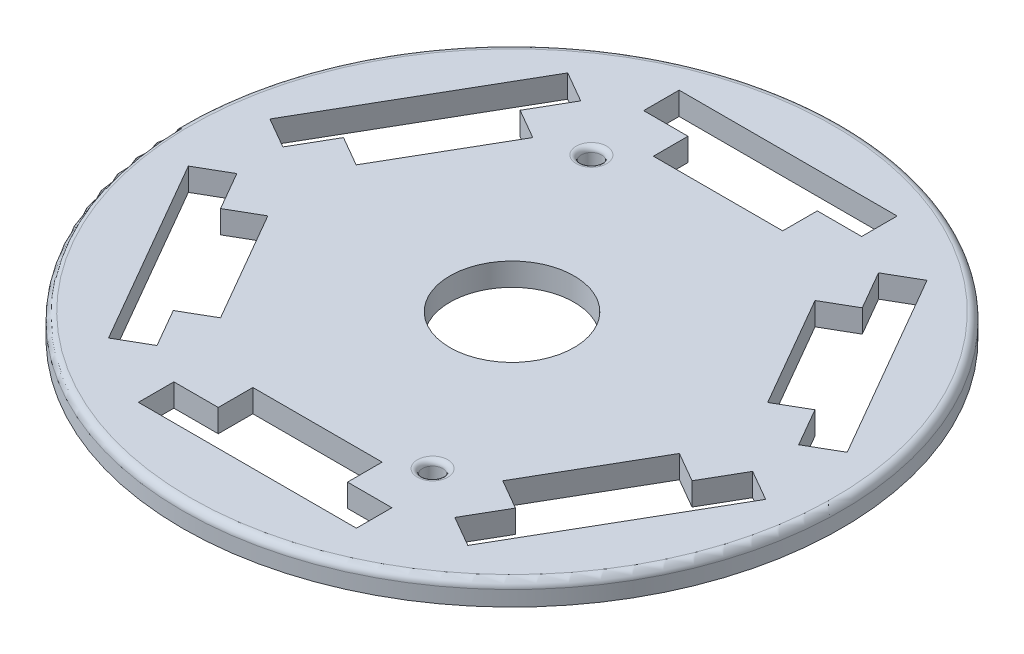
from build123d import *

# Parameters (mm, degrees)
SKETCH1_R           = 32.5
BOSS_EXTRUDE1_DEPTH = 2.25
SKETCH15_W          = 12.75
SKETCH15_H          = 3.5
CUT_EXTRUDE6_DEPTH  = 17
SKETCH17_W          = 21.5
SKETCH17_H          = 3.5
CUT_EXTRUDE7_DEPTH  = 12
SKETCH19_R          = 1
CUT_EXTRUDE9_DEPTH  = 16
FILLET4_R           = 0.5
FILLET5_R           = 0.5
SKETCH21_R          = 6.125
CUT_EXTRUDE11_DEPTH = 13
FILLET8_R           = 0.75


with BuildPart() as part:
    # Sketch1 → Boss-Extrude1 (new body)
    with BuildSketch(Plane(origin=(0, 0, 0), x_dir=(1, 0, 0), z_dir=(0, 1, 0))):
        Circle(SKETCH1_R)
    extrude(amount=BOSS_EXTRUDE1_DEPTH)

    # Sketch15 → Cut-Extrude6 (cut)
    with BuildSketch(Plane(origin=(0.067128405, 2.25, -0.501790944), x_dir=(1, 0, 0), z_dir=(0, 1, 0))):
        Polygon((-13.916501725, 15.395911949), (-20.291501725, 4.354088051), (-23.322590638, 6.104088051), (-16.947590638, 17.145911949), align=None)
        with Locations((0, 21.5)):
            Rectangle(SKETCH15_W, SKETCH15_H)
        Polygon((-20.291501725, -4.354088051), (-13.916501725, -15.395911949), (-16.947590638, -17.145911949), (-23.322590638, -6.104088051), align=None)
        with Locations((0, -21.5)):
            Rectangle(SKETCH15_W, SKETCH15_H)
        Polygon((13.916501725, -15.395911949), (20.291501725, -4.354088051), (23.322590638, -6.104088051), (16.947590638, -17.145911949), align=None)
        Polygon((20.291501725, 4.354088051), (13.916501725, 15.395911949), (16.947590638, 17.145911949), (23.322590638, 6.104088051), align=None)
    extrude(amount=-CUT_EXTRUDE6_DEPTH, mode=Mode.SUBTRACT)

    # Sketch17 → Cut-Extrude7 (cut)
    with BuildSketch(Plane(origin=(0.067128405, 2.25, -0.501790944), x_dir=(1, 0, 0), z_dir=(0, 1, 0))):
        Polygon((-17.715410458, -22.641027784), (-28.465410458, -4.021481603), (-25.434321545, -2.271481603), (-14.684321545, -20.891027784), align=None)
        with Locations((0, -24.912509387)):
            Rectangle(SKETCH17_W, SKETCH17_H)
        Polygon((-28.465410458, 4.021481603), (-17.715410458, 22.641027784), (-14.684321545, 20.891027784), (-25.434321545, 2.271481603), align=None)
        with Locations((0, 24.912509387)):
            Rectangle(SKETCH17_W, SKETCH17_H)
        Polygon((17.715410458, 22.641027784), (28.465410458, 4.021481603), (25.434321545, 2.271481603), (14.684321545, 20.891027784), align=None)
        Polygon((28.465410458, -4.021481603), (17.715410458, -22.641027784), (14.684321545, -20.891027784), (25.434321545, -2.271481603), align=None)
    extrude(amount=-CUT_EXTRUDE7_DEPTH, mode=Mode.SUBTRACT)

    # Sketch19 → Cut-Extrude9 (cut)
    with BuildSketch(Plane(origin=(0, 2.25, 0), x_dir=(1, 0, 0), z_dir=(0, 1, 0))):
        with Locations((-9.476258541, 17.306577458)):
            Circle(SKETCH19_R)
        with Locations((9.476258541, -17.306577458)):
            Circle(SKETCH19_R)
    extrude(amount=-CUT_EXTRUDE9_DEPTH, mode=Mode.SUBTRACT)

    # Fillet4
    fillet4_edges = [part.edges().sort_by_distance(p)[0] for p in [
        (-10.476258541, 2.25, -17.306577458),
        (8.476258541, 2.25, 17.306577458),
    ]]
    fillet(fillet4_edges, radius=FILLET4_R)

    # Fillet5
    fillet5_edges = [part.edges().sort_by_distance(p)[0] for p in [
        (-10.476258541, 0, -17.306577458),
        (8.476258541, 0, 17.306577458),
    ]]
    fillet(fillet5_edges, radius=FILLET5_R)

    # Sketch21 → Cut-Extrude11 (cut)
    with BuildSketch(Plane(origin=(0, 2.25, 0), x_dir=(1, 0, 0), z_dir=(0, 1, 0))):
        Circle(SKETCH21_R)
    extrude(amount=-CUT_EXTRUDE11_DEPTH, mode=Mode.SUBTRACT)

    # Fillet8
    fillet8_edges = [part.edges().sort_by_distance(p)[0] for p in [
        (-32.5, 2.25, 0),
    ]]
    fillet(fillet8_edges, radius=FILLET8_R)


solid = part.part
